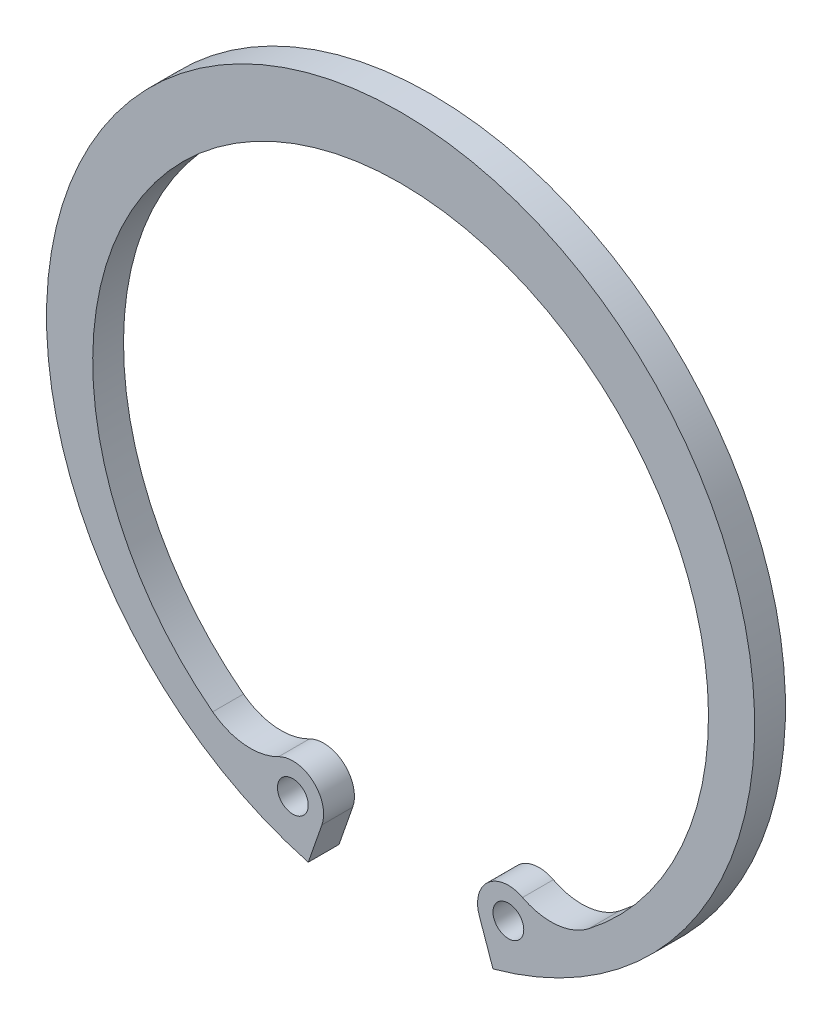
from build123d import *

# Parameters (mm, degrees)
SKETCH1_R           = 1
BOSS_EXTRUDE1_DEPTH = 2


with BuildPart() as part:
    # Sketch1 → Boss-Extrude1 (new body)
    with BuildSketch(Plane.XY):
        with BuildLine():
            Line((5.111751732, -19.659180157), (6, -22.203603311))
            ThreePointArc((6, -22.203603311), (0, 23), (-6, -22.203603311))
            Line((-6, -22.203603311), (-5.111751732, -19.659180157))
            ThreePointArc((-5.111751732, -19.659180157), (-5.690422868, -17.488375796), (-7.921535407, -17.224958453))
            ThreePointArc((-7.921535407, -17.224958453), (-10.119267773, -17.659121233), (-12.205757776, -16.843594198))
            ThreePointArc((-12.205757776, -16.843594198), (0, 19), (12.205757776, -16.843594198))
            ThreePointArc((12.205757776, -16.843594198), (10.119267773, -17.659121233), (7.921535407, -17.224958453))
            ThreePointArc((7.921535407, -17.224958453), (5.690422868, -17.488375796), (5.111751732, -19.659180157))
        make_face()
        with Locations((-7, -19)):
            Circle(SKETCH1_R, mode=Mode.SUBTRACT)
        with Locations((7, -19)):
            Circle(SKETCH1_R, mode=Mode.SUBTRACT)
    extrude(amount=BOSS_EXTRUDE1_DEPTH)


solid = part.part
